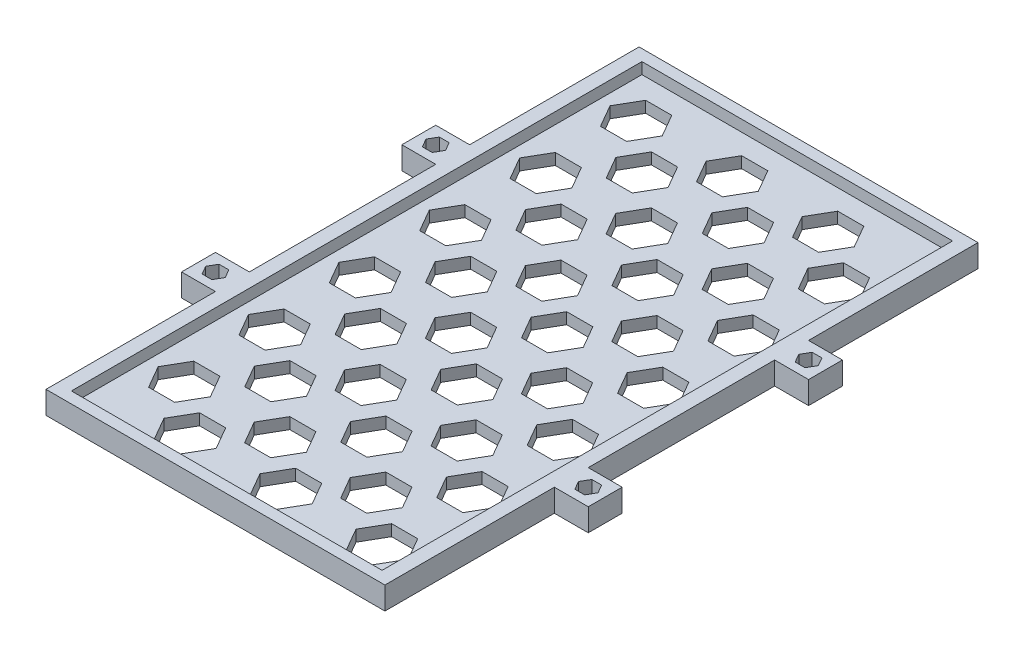
from build123d import *

# Parameters (mm, degrees)
SALIENTE_EXTRUIR1_DEPTH = 4
CROQUIS2_W              = 55
CROQUIS2_H              = 101
CORTAR_EXTRUIR1_DEPTH   = 2
CORTAR_EXTRUIR2_DEPTH   = 3


with BuildPart() as part:
    # Croquis1 → Saliente-Extruir1 (new body)
    with BuildSketch(Plane(origin=(0, 0, 0), x_dir=(1, 0, 0), z_dir=(0, 1, 0))):
        Polygon((30, -52.5), (30, -22.5), (36, -22.5), (36, -16.5), (30, -16.5), (30, 16.5), (36, 16.5), (36, 22.5), (30, 22.5), (30, 52.5), (-30, 52.5), (-30, 22.5), (-36, 22.5), (-36, 16.5), (-30, 16.5), (-30, -16.5), (-36, -16.5), (-36, -22.5), (-30, -22.5), (-30, -52.5), align=None)
        Polygon((31.267949192, -19.5), (32.133974596, -21), (33.866025404, -21), (34.732050808, -19.5), (33.866025404, -18), (32.133974596, -18), align=None, mode=Mode.SUBTRACT)
        Polygon((31.267949192, 19.5), (32.133974596, 18), (33.866025404, 18), (34.732050808, 19.5), (33.866025404, 21), (32.133974596, 21), align=None, mode=Mode.SUBTRACT)
        Polygon((-34.732050808, 19.5), (-33.866025404, 18), (-32.133974596, 18), (-31.267949192, 19.5), (-32.133974596, 21), (-33.866025404, 21), align=None, mode=Mode.SUBTRACT)
        Polygon((-34.732050808, -19.5), (-33.866025404, -21), (-32.133974596, -21), (-31.267949192, -19.5), (-32.133974596, -18), (-33.866025404, -18), align=None, mode=Mode.SUBTRACT)
    extrude(amount=SALIENTE_EXTRUIR1_DEPTH)

    # Croquis2 → Cortar-Extruir1 (cut)
    with BuildSketch(Plane(origin=(0, 4, 0), x_dir=(1, 0, 0), z_dir=(0, 1, 0))):
        Rectangle(CROQUIS2_W, CROQUIS2_H)
    extrude(amount=-CORTAR_EXTRUIR1_DEPTH, mode=Mode.SUBTRACT)

    # Croquis3 → Cortar-Extruir2 (cut, through all)
    with BuildSketch(Plane(origin=(0, 2, 0), x_dir=(1, 0, 0), z_dir=(0, 1, 0))):
        Polygon((-0.118802154, -44.5), (2.190598923, -48.5), (6.809401077, -48.5), (9.118802154, -44.5), (6.809401077, -40.5), (2.190598923, -40.5), align=None)
        Polygon((16.881197846, -44.5), (19.190598923, -48.5), (23.809401077, -48.5), (26.118802154, -44.5), (23.809401077, -40.5), (19.190598923, -40.5), align=None)
        Polygon((8.452994616, -37.098076211), (10.762395693, -41.098076211), (15.381197846, -41.098076211), (17.690598923, -37.098076211), (15.381197846, -33.098076211), (10.762395693, -33.098076211), align=None)
        Polygon((-8.547005384, -37.098076211), (-6.237604307, -41.098076211), (-1.618802154, -41.098076211), (0.690598923, -37.098076211), (-1.618802154, -33.098076211), (-6.237604307, -33.098076211), align=None)
        Polygon((-17.118802154, -44.5), (-14.809401077, -48.5), (-10.190598923, -48.5), (-7.881197846, -44.5), (-10.190598923, -40.5), (-14.809401077, -40.5), align=None)
        Polygon((-25.547005384, -37.098076211), (-23.237604307, -41.098076211), (-18.618802154, -41.098076211), (-16.309401077, -37.098076211), (-18.618802154, -33.098076211), (-23.237604307, -33.098076211), align=None)
        Polygon((-0.118802154, -28.5), (2.190598923, -32.5), (6.809401077, -32.5), (9.118802154, -28.5), (6.809401077, -24.5), (2.190598923, -24.5), align=None)
        Polygon((-8.547005384, -21.098076211), (-6.237604307, -25.098076211), (-1.618802154, -25.098076211), (0.690598923, -21.098076211), (-1.618802154, -17.098076211), (-6.237604307, -17.098076211), align=None)
        Polygon((-17.118802154, -28.5), (-14.809401077, -32.5), (-10.190598923, -32.5), (-7.881197846, -28.5), (-10.190598923, -24.5), (-14.809401077, -24.5), align=None)
        Polygon((-25.547005384, -21.098076211), (-23.237604307, -25.098076211), (-18.618802154, -25.098076211), (-16.309401077, -21.098076211), (-18.618802154, -17.098076211), (-23.237604307, -17.098076211), align=None)
        Polygon((-0.118802154, -12.5), (2.190598923, -16.5), (6.809401077, -16.5), (9.118802154, -12.5), (6.809401077, -8.5), (2.190598923, -8.5), align=None)
        Polygon((-8.547005384, -5.098076211), (-6.237604307, -9.098076211), (-1.618802154, -9.098076211), (0.690598923, -5.098076211), (-1.618802154, -1.098076211), (-6.237604307, -1.098076211), align=None)
        Polygon((-17.118802154, -12.5), (-14.809401077, -16.5), (-10.190598923, -16.5), (-7.881197846, -12.5), (-10.190598923, -8.5), (-14.809401077, -8.5), align=None)
        Polygon((-25.547005384, -5.098076211), (-23.237604307, -9.098076211), (-18.618802154, -9.098076211), (-16.309401077, -5.098076211), (-18.618802154, -1.098076211), (-23.237604307, -1.098076211), align=None)
        Polygon((-0.118802154, 3.5), (2.190598923, -0.5), (6.809401077, -0.5), (9.118802154, 3.5), (6.809401077, 7.5), (2.190598923, 7.5), align=None)
        Polygon((-8.547005384, 10.901923789), (-6.237604307, 6.901923789), (-1.618802154, 6.901923789), (0.690598923, 10.901923789), (-1.618802154, 14.901923789), (-6.237604307, 14.901923789), align=None)
        Polygon((-17.118802154, 3.5), (-14.809401077, -0.5), (-10.190598923, -0.5), (-7.881197846, 3.5), (-10.190598923, 7.5), (-14.809401077, 7.5), align=None)
        Polygon((-25.547005384, 10.901923789), (-23.237604307, 6.901923789), (-18.618802154, 6.901923789), (-16.309401077, 10.901923789), (-18.618802154, 14.901923789), (-23.237604307, 14.901923789), align=None)
        Polygon((-0.118802154, 19.5), (2.190598923, 15.5), (6.809401077, 15.5), (9.118802154, 19.5), (6.809401077, 23.5), (2.190598923, 23.5), align=None)
        Polygon((-8.547005384, 26.901923789), (-6.237604307, 22.901923789), (-1.618802154, 22.901923789), (0.690598923, 26.901923789), (-1.618802154, 30.901923789), (-6.237604307, 30.901923789), align=None)
        Polygon((-17.118802154, 19.5), (-14.809401077, 15.5), (-10.190598923, 15.5), (-7.881197846, 19.5), (-10.190598923, 23.5), (-14.809401077, 23.5), align=None)
        Polygon((-25.547005384, 26.901923789), (-23.237604307, 22.901923789), (-18.618802154, 22.901923789), (-16.309401077, 26.901923789), (-18.618802154, 30.901923789), (-23.237604307, 30.901923789), align=None)
        Polygon((-0.118802154, 35.5), (2.190598923, 31.5), (6.809401077, 31.5), (9.118802154, 35.5), (6.809401077, 39.5), (2.190598923, 39.5), align=None)
        Polygon((-8.547005384, 42.901923789), (-6.237604307, 38.901923789), (-1.618802154, 38.901923789), (0.690598923, 42.901923789), (-1.618802154, 46.901923789), (-6.237604307, 46.901923789), align=None)
        Polygon((-17.118802154, 35.5), (-14.809401077, 31.5), (-10.190598923, 31.5), (-7.881197846, 35.5), (-10.190598923, 39.5), (-14.809401077, 39.5), align=None)
        Polygon((-25.547005384, 42.901923789), (-23.237604307, 38.901923789), (-18.618802154, 38.901923789), (-16.309401077, 42.901923789), (-18.618802154, 46.901923789), (-23.237604307, 46.901923789), align=None)
        Polygon((16.881197846, -28.5), (19.190598923, -32.5), (23.809401077, -32.5), (26.118802154, -28.5), (23.809401077, -24.5), (19.190598923, -24.5), align=None)
        Polygon((8.452994616, -21.098076211), (10.762395693, -25.098076211), (15.381197846, -25.098076211), (17.690598923, -21.098076211), (15.381197846, -17.098076211), (10.762395693, -17.098076211), align=None)
        Polygon((16.881197846, -12.5), (19.190598923, -16.5), (23.809401077, -16.5), (26.118802154, -12.5), (23.809401077, -8.5), (19.190598923, -8.5), align=None)
        Polygon((8.452994616, -5.098076211), (10.762395693, -9.098076211), (15.381197846, -9.098076211), (17.690598923, -5.098076211), (15.381197846, -1.098076211), (10.762395693, -1.098076211), align=None)
        Polygon((16.881197846, 3.5), (19.190598923, -0.5), (23.809401077, -0.5), (26.118802154, 3.5), (23.809401077, 7.5), (19.190598923, 7.5), align=None)
        Polygon((8.452994616, 10.901923789), (10.762395693, 6.901923789), (15.381197846, 6.901923789), (17.690598923, 10.901923789), (15.381197846, 14.901923789), (10.762395693, 14.901923789), align=None)
        Polygon((16.881197846, 19.5), (19.190598923, 15.5), (23.809401077, 15.5), (26.118802154, 19.5), (23.809401077, 23.5), (19.190598923, 23.5), align=None)
        Polygon((8.452994616, 26.901923789), (10.762395693, 22.901923789), (15.381197846, 22.901923789), (17.690598923, 26.901923789), (15.381197846, 30.901923789), (10.762395693, 30.901923789), align=None)
        Polygon((16.881197846, 35.5), (19.190598923, 31.5), (23.809401077, 31.5), (26.118802154, 35.5), (23.809401077, 39.5), (19.190598923, 39.5), align=None)
        Polygon((8.452994616, 42.901923789), (10.762395693, 38.901923789), (15.381197846, 38.901923789), (17.690598923, 42.901923789), (15.381197846, 46.901923789), (10.762395693, 46.901923789), align=None)
    extrude(amount=-CORTAR_EXTRUIR2_DEPTH, mode=Mode.SUBTRACT)


solid = part.part
